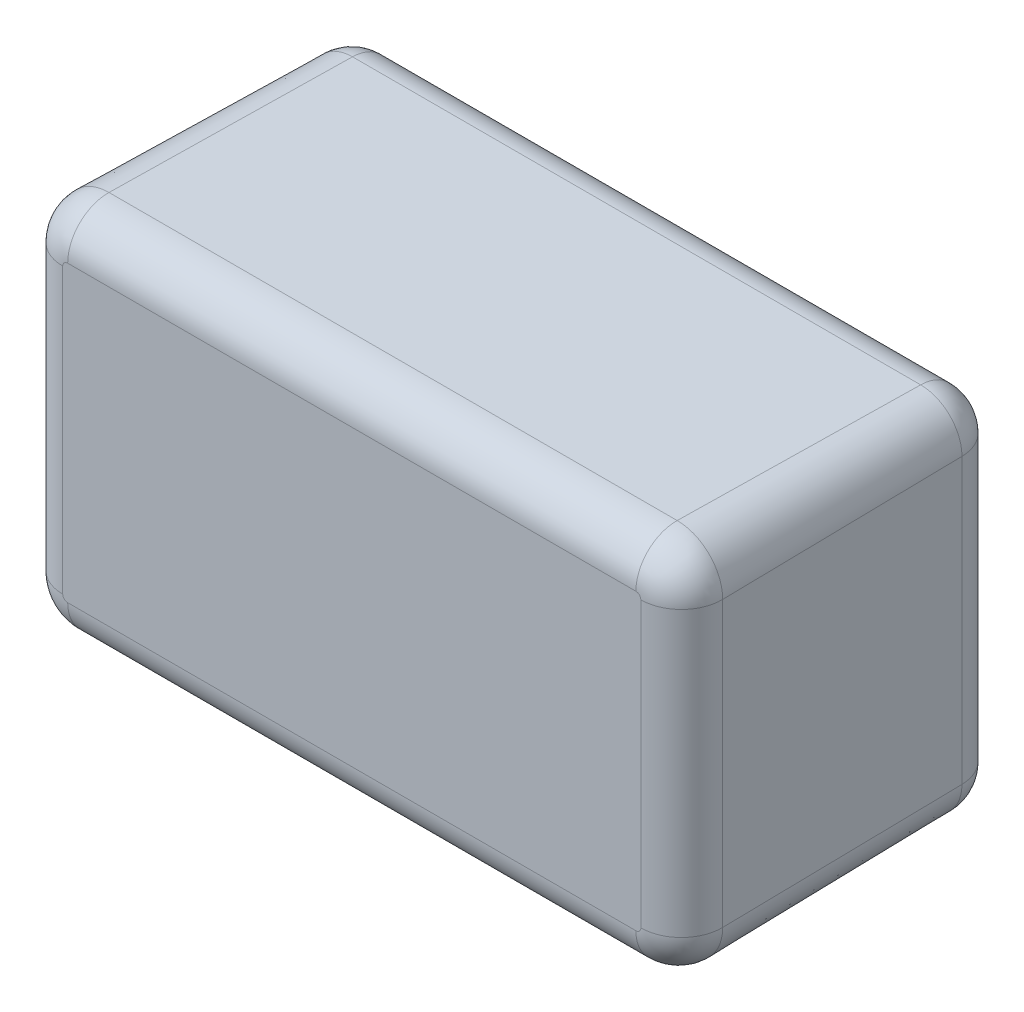
from build123d import *

# Parameters (mm, degrees)
BOSS_EXTRUDE1_DEPTH = 80
DRAFT1_ANGLE        = 1
FILLET1_R           = 10
SHELL2_T            = 2.5


with BuildPart() as part:
    # Sketch1 → Boss-Extrude1 (new body)
    with BuildSketch(Plane.XY):
        with BuildLine():
            Line((-70, 45), (70, 45))
            ThreePointArc((70, 45), (77.071067812, 42.071067812), (80, 35))
            Line((80, 35), (80, -35))
            ThreePointArc((80, -35), (77.071067812, -42.071067812), (70, -45))
            Line((70, -45), (-70, -45))
            ThreePointArc((-70, -45), (-77.071067812, -42.071067812), (-80, -35))
            Line((-80, -35), (-80, 35))
            ThreePointArc((-80, 35), (-77.071067812, 42.071067812), (-70, 45))
        make_face()
    extrude(amount=BOSS_EXTRUDE1_DEPTH)

    # Draft1
    draft1_faces = [part.faces().sort_by_distance(p)[0] for p in [
        (-77.071067812, -42.071067812, 40),
        (-77.071067812, 42.071067812, 40),
        (77.071067812, 42.071067812, 40),
        (77.071067812, -42.071067812, 40),
        (80, 0, 40),
        (0, -45, 40),
        (-80, 0, 40),
        (0, 45, 40),
    ]]
    draft(draft1_faces, Plane(origin=(-70, 35, 0), x_dir=(-1, 0, 0), z_dir=(0, 0, -1)), DRAFT1_ANGLE)

    # Fillet1
    fillet1_edges = [part.edges().sort_by_distance(p)[0] for p in [
        (0, -45, 0),
        (-77.071067812, -42.071067812, 0),
        (-80, 0, 0),
        (-77.071067812, 42.071067812, 0),
        (-78.058475394, -43.058475394, 80),
        (0, -46.396405194, 80),
        (78.058475394, -43.058475394, 80),
        (81.396405194, 0, 80),
        (78.058475394, 43.058475394, 80),
        (0, 46.396405194, 80),
        (-78.058475394, 43.058475394, 80),
        (0, 45, 0),
        (-81.396405194, 0, 80),
        (77.071067812, 42.071067812, 0),
        (80, 0, 0),
        (77.071067812, -42.071067812, 0),
    ]]
    fillet(fillet1_edges, radius=FILLET1_R)

    # Shell2 (no face opened: a closed hollow body)
    add(offset(amount=-SHELL2_T, mode=Mode.PRIVATE), mode=Mode.SUBTRACT)


solid = part.part
